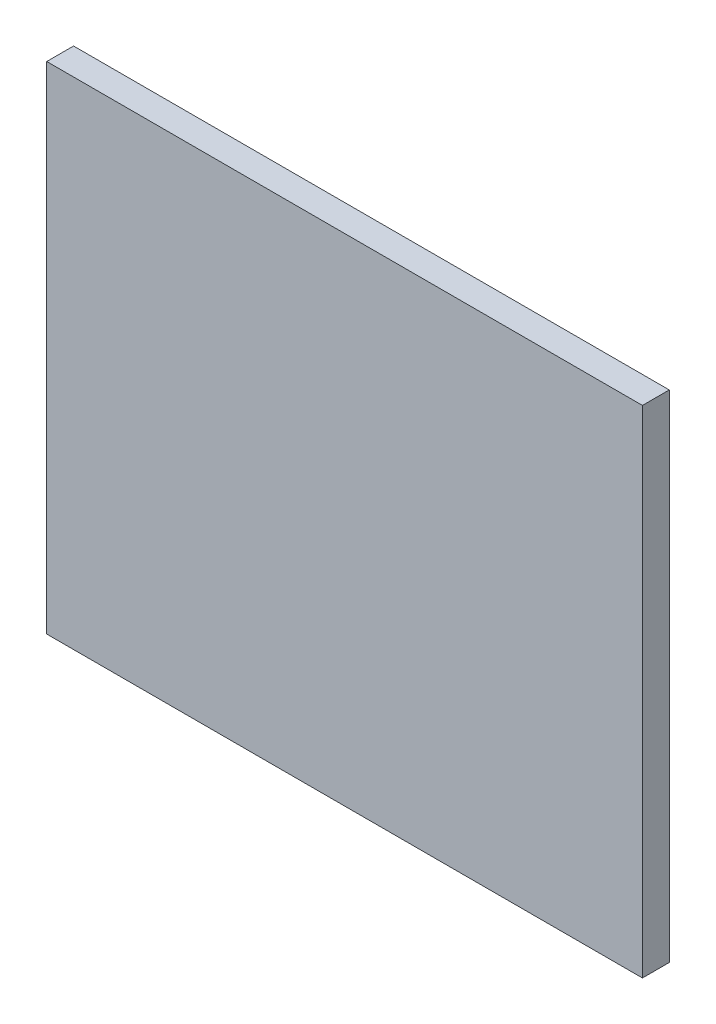
from build123d import *

# Parameters (mm, degrees)
CROQUIS1_W              = 111
CROQUIS1_H              = 92.4
SALIENTE_EXTRUIR1_DEPTH = 5


with BuildPart() as part:
    # Croquis1 → Saliente-Extruir1 (new body)
    with BuildSketch(Plane.XY):
        with Locations((55.5, 46.2)):
            Rectangle(CROQUIS1_W, CROQUIS1_H)
    extrude(amount=SALIENTE_EXTRUIR1_DEPTH)


solid = part.part
